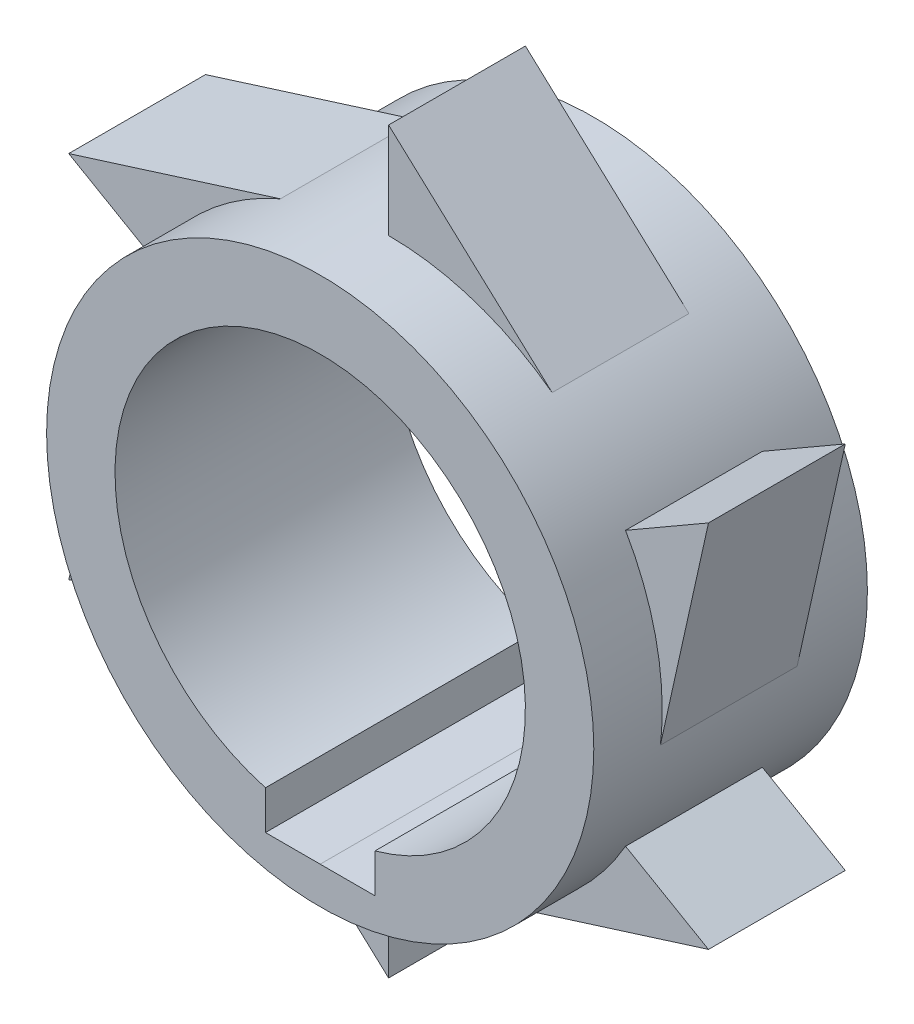
from build123d import *

# Parameters (mm, degrees)
SKETCH1_R               = 20
SKETCH1_R_2             = 15
BOSS_EXTRUDE1_DEPTH     = 20
CUT_EXTRUDE2_DEPTH      = 21
CUT_EXTRUDE2_DEPTH_BACK = 1
BOSS_EXTRUDE16_DEPTH    = 10
CIRPATTERN2_COUNT       = 6


with BuildPart() as part:
    # Sketch1 → Boss-Extrude1 (new body)
    with BuildSketch(Plane.XY):
        Circle(SKETCH1_R)
        Circle(SKETCH1_R_2, mode=Mode.SUBTRACT)
    extrude(amount=BOSS_EXTRUDE1_DEPTH)

    # Sketch5 → Cut-Extrude2 (cut, two sides)
    with BuildSketch(Plane.XY) as cut_extrude2_sk:
        with BuildLine():
            Line((-4, -17.293255897), (0, -17.293255897))
            Line((0, -17.293255897), (4, -17.293255897))
            Line((4, -17.293255897), (4, -14.456832295))
            ThreePointArc((4, -14.456832295), (0, -15), (-4, -14.456832295))
            Line((-4, -14.456832295), (-4, -17.293255897))
        make_face()
    extrude(amount=CUT_EXTRUDE2_DEPTH, mode=Mode.SUBTRACT)
    extrude(cut_extrude2_sk.sketch, amount=-CUT_EXTRUDE2_DEPTH_BACK, mode=Mode.SUBTRACT)

    # Sketch18 → Boss-Extrude16 (add)
    with BuildSketch(Plane.XY.offset(5)):
        with BuildLine():
            Line((0, 27), (0, 20))
            ThreePointArc((0, 20), (6.296505517, 18.982992869), (11.952651932, 16.035401828))
            Line((11.952651932, 16.035401828), (0, 27))
        make_face()
    boss_extrude16 = extrude(amount=BOSS_EXTRUDE16_DEPTH)

    # CirPattern2: Boss-Extrude16 ×6 about axis
    cirpattern2_axis = Axis((0, 0, 0), (0, 0, 1))
    for i in range(1, CIRPATTERN2_COUNT):
        add(boss_extrude16.rotate(cirpattern2_axis, i * 360 / CIRPATTERN2_COUNT))


solid = part.part
